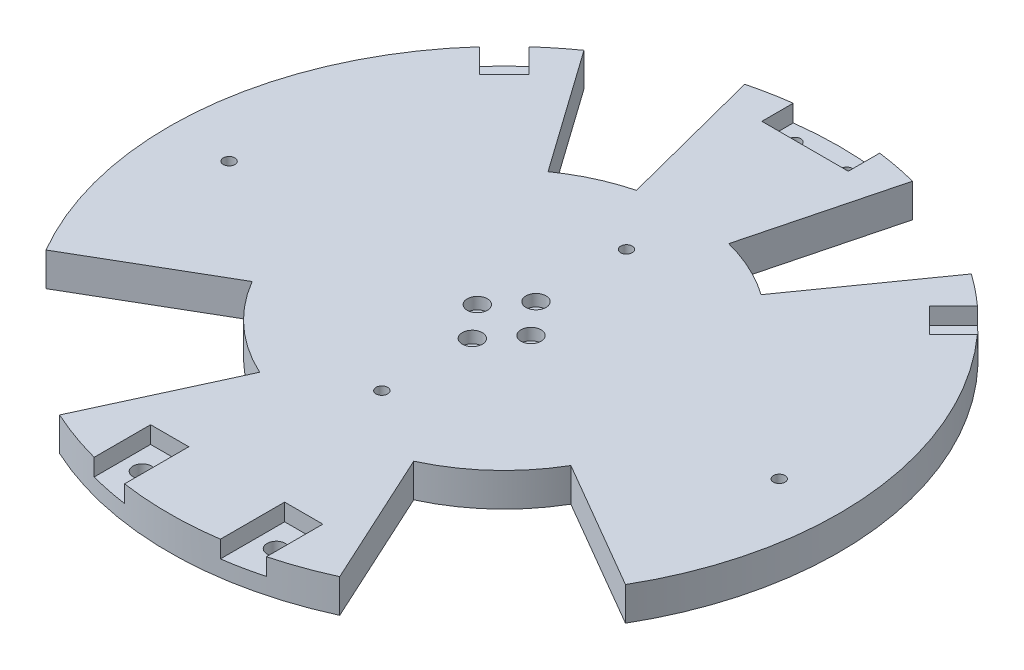
from build123d import *

# Parameters (mm, degrees)
SKETCH1_R           = 100
BOSS_EXTRUDE1_DEPTH = 10
SKETCH4_R           = 1.73
CUT_EXTRUDE2_DEPTH  = 11
SKETCH6_R           = 1.75
CUT_EXTRUDE3_DEPTH  = 10
SKETCH7_R           = 3
CUT_EXTRUDE4_DEPTH  = 3.5
CUT_EXTRUDE5_DEPTH  = 5.1
CUT_EXTRUDE6_DEPTH  = 5.1
SKETCH10_R          = 1.75
CUT_EXTRUDE7_DEPTH  = 5.9
CUT_EXTRUDE9_DEPTH  = 5.1
SKETCH13_R          = 1.75
CUT_EXTRUDE10_DEPTH = 5.9
CUT_EXTRUDE11_DEPTH = 11
CUT_EXTRUDE12_DEPTH = 11
SKETCH18_R          = 2.75
CUT_EXTRUDE13_DEPTH = 5.9


with BuildPart() as part:
    # Sketch1 → Boss-Extrude1 (new body)
    with BuildSketch(Plane(origin=(0, 0, 0), x_dir=(1, 0, 0), z_dir=(0, 1, 0))):
        Circle(SKETCH1_R)
    extrude(amount=BOSS_EXTRUDE1_DEPTH)

    # Sketch4 → Cut-Extrude2 (cut, through all)
    with BuildSketch(Plane(origin=(0, 10, 0), x_dir=(1, 0, 0), z_dir=(0, 1, 0))):
        with Locations((-82.085, 0)):
            Circle(SKETCH4_R)
        with Locations((0, -36.5)):
            Circle(SKETCH4_R)
        with Locations((82.085, 0)):
            Circle(SKETCH4_R)
        with Locations((0, 36.5)):
            Circle(SKETCH4_R)
    extrude(amount=-CUT_EXTRUDE2_DEPTH, mode=Mode.SUBTRACT)

    # Sketch6 → Cut-Extrude3 (cut)
    with BuildSketch(Plane.XZ):
        with Locations((8, 0)):
            Circle(SKETCH6_R)
        with Locations((0, 9.5)):
            Circle(SKETCH6_R)
        with Locations((-8, 0)):
            Circle(SKETCH6_R)
        with Locations((0, -9.5)):
            Circle(SKETCH6_R)
    extrude(amount=-CUT_EXTRUDE3_DEPTH, mode=Mode.SUBTRACT)

    # Sketch7 → Cut-Extrude4 (cut)
    with BuildSketch(Plane(origin=(0, 10, 0), x_dir=(1, 0, 0), z_dir=(0, 1, 0))):
        with Locations((0, 9.5)):
            Circle(SKETCH7_R)
        with Locations((-8, 0)):
            Circle(SKETCH7_R)
        with Locations((0, -9.5)):
            Circle(SKETCH7_R)
        with Locations((8, 0)):
            Circle(SKETCH7_R)
    extrude(amount=-CUT_EXTRUDE4_DEPTH, mode=Mode.SUBTRACT)

    # Sketch8 → Cut-Extrude5 (cut)
    with BuildSketch(Plane(origin=(0, 10, 0), x_dir=(1, 0, 0), z_dir=(0, 1, 0))):
        with BuildLine():
            Line((-14.3, -79.8), (-14.3, -99.17434144))
            ThreePointArc((-14.3, -99.17434144), (-20.033793367, -98.17681561), (-25.7, -96.848076904))
            Line((-25.7, -96.848076904), (-25.7, -79.8))
            Line((-25.7, -79.8), (-14.3, -79.8))
        make_face()
        with BuildLine():
            Line((25.7, -79.8), (25.7, -96.848076904))
            ThreePointArc((25.7, -96.848076904), (20.033793367, -98.17681561), (14.3, -99.17434144))
            Line((14.3, -99.17434144), (14.3, -79.8))
            Line((14.3, -79.8), (25.7, -79.8))
        make_face()
    extrude(amount=-CUT_EXTRUDE5_DEPTH, mode=Mode.SUBTRACT)

    # Sketch9 → Cut-Extrude6 (cut)
    with BuildSketch(Plane(origin=(0, 10, 0), x_dir=(1, 0, 0), z_dir=(0, 1, 0))):
        with BuildLine():
            Line((-12.9, 99.164459359), (-12.9, 89.8))
            Line((-12.9, 89.8), (12.9, 89.8))
            Line((12.9, 89.8), (12.9, 99.164459359))
            ThreePointArc((12.9, 99.164459359), (0, 100), (-12.9, 99.164459359))
        make_face()
    extrude(amount=-CUT_EXTRUDE6_DEPTH, mode=Mode.SUBTRACT)

    # Sketch10 → Cut-Extrude7 (cut, through all)
    with BuildSketch(Plane(origin=(0, 4.9, 0), x_dir=(1, 0, 0), z_dir=(0, 1, 0))):
        with Locations((-7.7, 94.48222968)):
            Circle(SKETCH10_R)
        with Locations((7.7, 94.48222968)):
            Circle(SKETCH10_R)
    extrude(amount=-CUT_EXTRUDE7_DEPTH, mode=Mode.SUBTRACT)

    # Sketch12 → Cut-Extrude9 (cut)
    with BuildSketch(Plane(origin=(0, 10, 0), x_dir=(1, 0, 0), z_dir=(0, 1, 0))):
        with BuildLine():
            Line((67.079669869, 74.433580394), (59.821233688, 67.175144213))
            Line((59.821233688, 67.175144213), (67.175144213, 59.821233688))
            Line((67.175144213, 59.821233688), (74.433580394, 67.079669869))
            ThreePointArc((74.433580394, 67.079669869), (70.852099475, 70.852099475), (67.079669869, 74.433580394))
        make_face()
    cut_extrude9 = extrude(amount=-CUT_EXTRUDE9_DEPTH, mode=Mode.SUBTRACT)

    # Sketch13 → Cut-Extrude10 (cut, through all)
    with BuildSketch(Plane(origin=(0, 4.9, 0), x_dir=(1, 0, 0), z_dir=(0, 1, 0))):
        with Locations((67.175144213, 67.175144213)):
            Circle(SKETCH13_R)
    cut_extrude10 = extrude(amount=-CUT_EXTRUDE10_DEPTH, mode=Mode.SUBTRACT)

    # Mirror1: Cut-Extrude9, Cut-Extrude10 across plane
    add(cut_extrude9.mirror(Plane(origin=(0, 0, 0), x_dir=(0, 0, 1), z_dir=(1, 0, 0))), mode=Mode.SUBTRACT)
    add(cut_extrude10.mirror(Plane(origin=(0, 0, 0), x_dir=(0, 0, 1), z_dir=(1, 0, 0))), mode=Mode.SUBTRACT)

    # Sketch15 → Cut-Extrude11 (cut, through all)
    with BuildSketch(Plane(origin=(0, 10, 0), x_dir=(1, 0, 0), z_dir=(0, 1, 0))):
        with BuildLine():
            Line((-22.984410516, -49.967157946), (-41.789837303, -90.849378084))
            ThreePointArc((-41.789837303, -90.849378084), (-67.258268931, -74.002197673), (-86.455078863, -50.254545455))
            Line((-86.455078863, -50.254545455), (-47.550293374, -27.64))
            ThreePointArc((-47.550293374, -27.64), (-36.992047912, -40.70120872), (-22.984410516, -49.967157946))
        make_face()
        with BuildLine():
            Line((22.984410516, -49.967157946), (41.789837303, -90.849378084))
            ThreePointArc((41.789837303, -90.849378084), (67.258268931, -74.002197673), (86.455078863, -50.254545455))
            Line((86.455078863, -50.254545455), (47.550293374, -27.64))
            ThreePointArc((47.550293374, -27.64), (36.992047912, -40.70120872), (22.984410516, -49.967157946))
        make_face()
    extrude(amount=-CUT_EXTRUDE11_DEPTH, mode=Mode.SUBTRACT)

    # Sketch17 → Cut-Extrude12 (cut, through all)
    with BuildSketch(Plane(origin=(0, 10, 0), x_dir=(1, 0, 0), z_dir=(0, 1, 0))):
        with BuildLine():
            Line((-31.784523452, 44.885900558), (-57.79004264, 81.610728288))
            ThreePointArc((-57.79004264, 81.610728288), (-42.108464674, 90.7021345), (-25.043347605, 96.813381))
            Line((-25.043347605, 96.813381), (-13.773841183, 53.24735955))
            ThreePointArc((-13.773841183, 53.24735955), (-23.159655571, 49.886173975), (-31.784523452, 44.885900558))
        make_face()
        with BuildLine():
            Line((13.773841183, 53.24735955), (25.043347605, 96.813381))
            ThreePointArc((25.043347605, 96.813381), (42.108464674, 90.7021345), (57.79004264, 81.610728288))
            Line((57.79004264, 81.610728288), (31.784523452, 44.885900558))
            ThreePointArc((31.784523452, 44.885900558), (23.159655571, 49.886173975), (13.773841183, 53.24735955))
        make_face()
    extrude(amount=-CUT_EXTRUDE12_DEPTH, mode=Mode.SUBTRACT)

    # Sketch18 → Cut-Extrude13 (cut, through all)
    with BuildSketch(Plane(origin=(0, 4.9, 0), x_dir=(1, 0, 0), z_dir=(0, 1, 0))):
        with Locations((-20, -88)):
            Circle(SKETCH18_R)
        with Locations((20, -88)):
            Circle(SKETCH18_R)
    extrude(amount=-CUT_EXTRUDE13_DEPTH, mode=Mode.SUBTRACT)


solid = part.part
